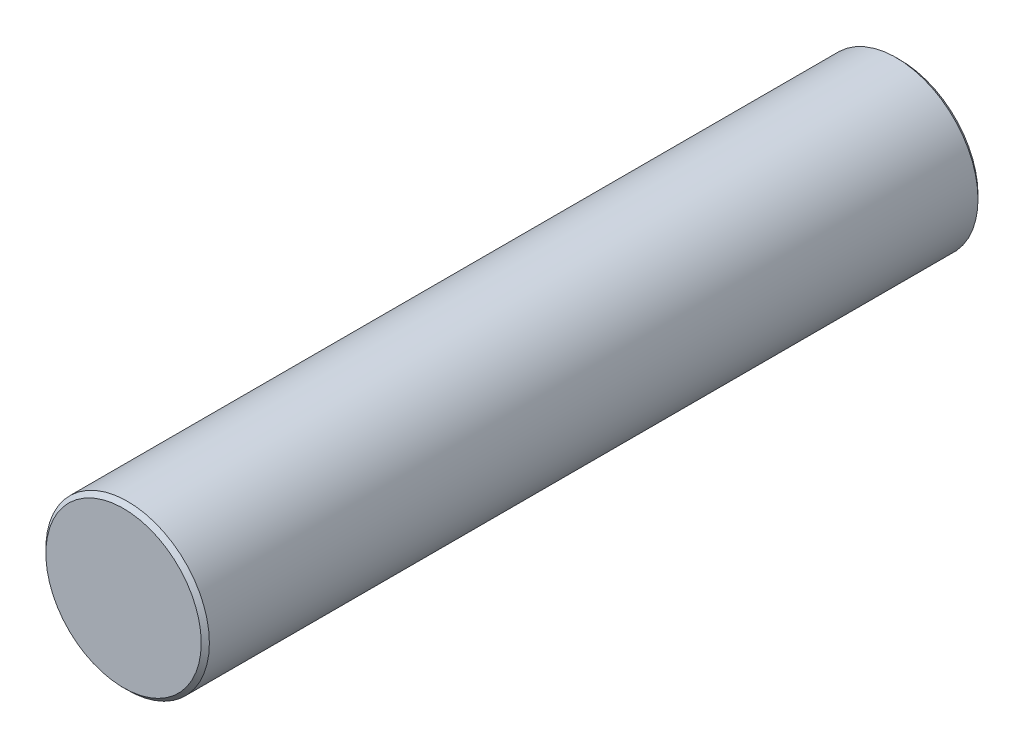
from build123d import *

# Parameters (mm, degrees)
SKETCH1_R           = 20
BOSS_EXTRUDE1_DEPTH = 190
CHAMFER1_SIZE       = 1


with BuildPart() as part:
    # Sketch1 → Boss-Extrude1 (new body)
    with BuildSketch(Plane.XY):
        Circle(SKETCH1_R)
    extrude(amount=BOSS_EXTRUDE1_DEPTH)

    # Chamfer1
    chamfer1_edges = [part.edges().sort_by_distance(p)[0] for p in [
        (-20, 0, 0),
        (-20, 0, 190),
    ]]
    chamfer(chamfer1_edges, length=CHAMFER1_SIZE)


solid = part.part
